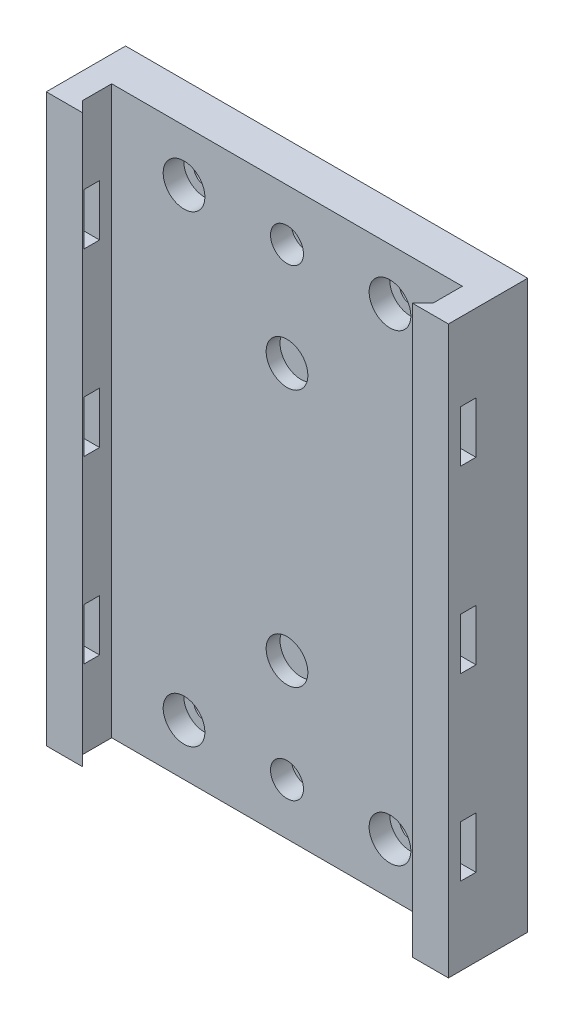
from build123d import *

# Parameters (mm, degrees)
SKETCH1_W                = 68.1
SKETCH1_H                = 110
SKETCH1_R                = 2.1
SKETCH1_R_2              = 4.05
SKETCH1_R_3              = 1.6
BOSS_EXTRUDE1_DEPTH      = 7.7
SKETCH2_R                = 7.334333348
SKETCH2_R_2              = 11.073656437
BOSS_EXTRUDE2_DEPTH      = 5
SKETCH3_R                = 4.05
SKETCH3_R_2              = 3.2
CUT_EXTRUDE1_DEPTH       = 4
SKETCH4_W                = 68.1
SKETCH4_H                = 5
BOSS_EXTRUDE3_DEPTH      = 7.7
BOSS_EXTRUDE3_DEPTH_BACK = 7.7
BOSS_EXTRUDE4_DEPTH      = 115
SKETCH8_W                = 94.544818424
SKETCH8_H                = 30.580965824
CUT_EXTRUDE2_DEPTH       = 10
SKETCH9_W                = 3
SKETCH9_H                = 10
CUT_EXTRUDE3_DEPTH       = 79.1


with BuildPart() as part:
    # Sketch1 → Boss-Extrude1 (new body)
    with BuildSketch(Plane.XY):
        Rectangle(SKETCH1_W, SKETCH1_H)
        with Locations((20, 45)):
            Circle(SKETCH1_R, mode=Mode.SUBTRACT)
        with Locations((-20, 45)):
            Circle(SKETCH1_R, mode=Mode.SUBTRACT)
        with Locations((20, -45)):
            Circle(SKETCH1_R, mode=Mode.SUBTRACT)
        with Locations((-20, -45)):
            Circle(SKETCH1_R, mode=Mode.SUBTRACT)
        with Locations((0, 25)):
            Circle(SKETCH1_R_2, mode=Mode.SUBTRACT)
        with Locations((0, -25)):
            Circle(SKETCH1_R_2, mode=Mode.SUBTRACT)
        with Locations((0, 45)):
            Circle(SKETCH1_R_3, mode=Mode.SUBTRACT)
        with Locations((0, -45)):
            Circle(SKETCH1_R_3, mode=Mode.SUBTRACT)
    extrude(amount=BOSS_EXTRUDE1_DEPTH)

    # Sketch2 → Boss-Extrude2 (add)
    with BuildSketch(Plane(origin=(0, 0, 0), x_dir=(-1, 0, 0), z_dir=(0, 0, -1))):
        with Locations((0, 25)):
            Circle(SKETCH2_R)
        with Locations((0, -25)):
            Circle(SKETCH2_R_2)
    extrude(amount=-BOSS_EXTRUDE2_DEPTH)

    # Sketch3 → Cut-Extrude1 (cut)
    with BuildSketch(Plane(origin=(0, 0, 7.7), x_dir=(-1, 0, 0), z_dir=(0, 0, -1))):
        with Locations((-20, 45)):
            Circle(SKETCH3_R)
        with Locations((20, 45)):
            Circle(SKETCH3_R)
        with Locations((-20, -45)):
            Circle(SKETCH3_R)
        with Locations((20, -45)):
            Circle(SKETCH3_R)
        with Locations((0, 45)):
            Circle(SKETCH3_R_2)
        with Locations((0, -45)):
            Circle(SKETCH3_R_2)
    extrude(amount=CUT_EXTRUDE1_DEPTH, mode=Mode.SUBTRACT)

    # Sketch4 → Boss-Extrude3 (add, two sides)
    with BuildSketch(Plane.XY.offset(7.7)) as boss_extrude3_sk:
        with Locations((0, 57.5)):
            Rectangle(SKETCH4_W, SKETCH4_H)
    extrude(amount=BOSS_EXTRUDE3_DEPTH)
    extrude(boss_extrude3_sk.sketch, amount=-BOSS_EXTRUDE3_DEPTH_BACK)

    # Sketch7 → Boss-Extrude4 (add)
    with BuildSketch(Plane.XZ.offset(55)):
        Polygon((-34.05, 15.4), (-32.05, 15.4), (-34.05, 13.4), (-34.05, 0), (-39.05, 0), (-39.05, 15.4), align=None)
        Polygon((39.05, 0), (34.05, 0), (34.05, 13.4), (32.05, 15.4), (34.05, 15.4), (39.05, 15.4), align=None)
    extrude(amount=-BOSS_EXTRUDE4_DEPTH)

    # Sketch8 → Cut-Extrude2 (cut)
    with BuildSketch(Plane.XZ.offset(-55)):
        with Locations((-0.280192095, 7.459835347)):
            Rectangle(SKETCH8_W, SKETCH8_H)
    extrude(amount=-CUT_EXTRUDE2_DEPTH, mode=Mode.SUBTRACT)

    # Sketch9 → Cut-Extrude3 (cut, through all)
    with BuildSketch(Plane.ZY.offset(39.05)):
        with Locations((11.55, 0)):
            Rectangle(SKETCH9_W, SKETCH9_H)
        with Locations((11.55, 34.9)):
            Rectangle(SKETCH9_W, SKETCH9_H)
        with Locations((11.55, -34.9)):
            Rectangle(SKETCH9_W, SKETCH9_H)
    extrude(amount=-CUT_EXTRUDE3_DEPTH, mode=Mode.SUBTRACT)


solid = part.part
